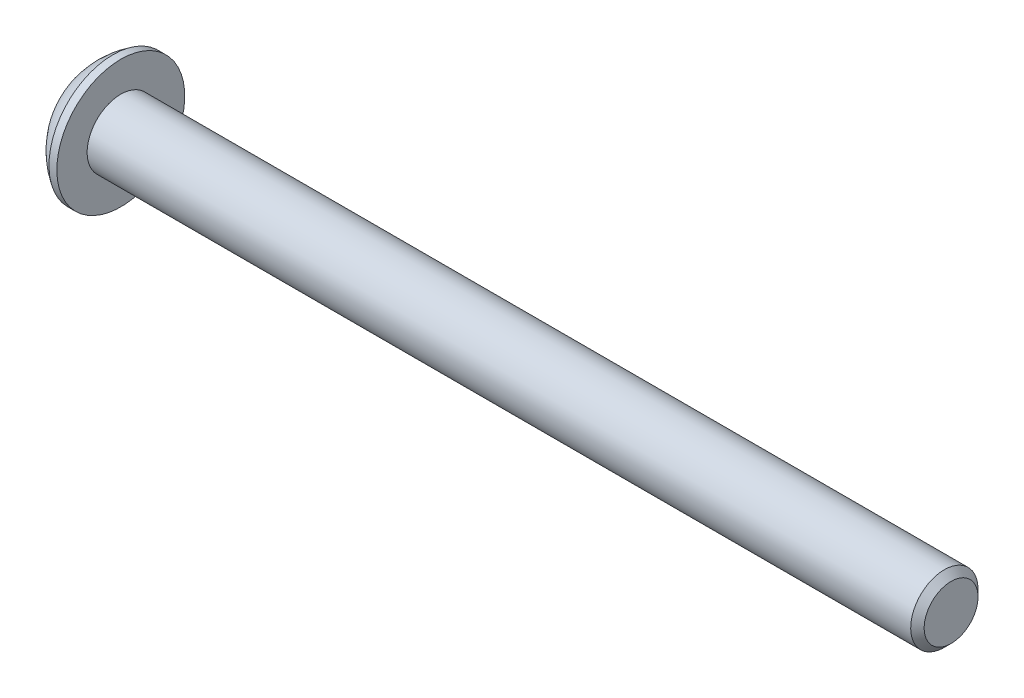
from build123d import *

# Parameters (mm, degrees)
CHAMFER1_SIZE      = 0.3
CUT_EXTRUDE1_DEPTH = 1
SCALE1_SCALE       = 1.667


with BuildPart() as part:
    # Sketch1 → Revolve1 (revolve)
    with BuildSketch(Plane.XY):
        with BuildLine():
            Line((38.65, 0), (0, 0))
            Line((0, 0), (0, 1.425))
            ThreePointArc((0, 1.425), (0.549895392, 2.228823502), (1.3, 2.85))
            Line((1.3, 2.85), (1.65, 2.85))
            Line((1.65, 2.85), (1.65, 1.5))
            Line((1.65, 1.5), (38.65, 1.5))
            Line((38.65, 1.5), (38.65, 0))
        make_face()
    revolve(axis=Axis((38.65, 0, 0), (-1, 0, 0)))

    # Chamfer1
    chamfer1_edges = [part.edges().sort_by_distance(p)[0] for p in [
        (38.65, -1.5, 0),
    ]]
    chamfer(chamfer1_edges, length=CHAMFER1_SIZE)

    # Sketch2 → Cut-Extrude1 (cut)
    with BuildSketch(Plane.ZY):
        Polygon((0, 1.154700538), (-1, 0.577350269), (-1, -0.577350269), (0, -1.154700538), (1, -0.577350269), (1, 0.577350269), align=None)
    extrude(amount=-CUT_EXTRUDE1_DEPTH, mode=Mode.SUBTRACT)


with BuildPart() as part_1:
    # Scale1: scaled about (18.321522069, 0, 0)
    add(part.part.scale(SCALE1_SCALE).moved(Location((-12.22045522, 0, 0))))


solid = part_1.part
